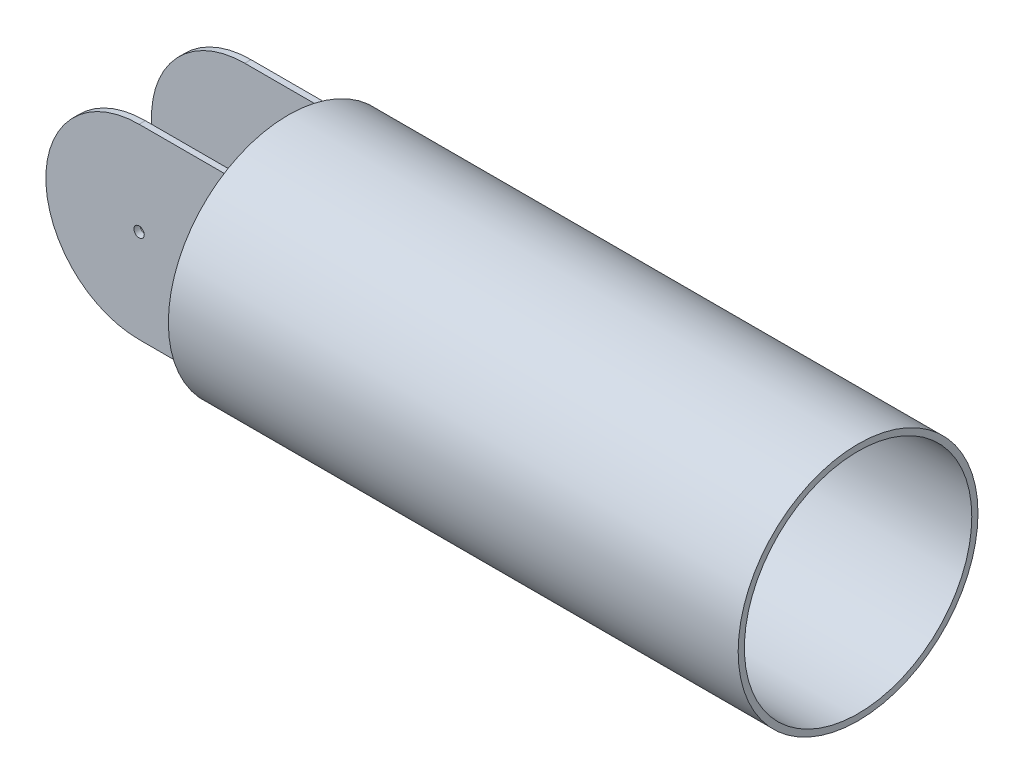
from build123d import *

# Parameters (mm, degrees)
IZIM10_W                    = 180
IZIM10_H                    = 180
Y_KSEKLIK_EKSTR_ZYON1_DEPTH = 108
KES_EKSTR_ZYON7_DEPTH       = 108
IZIM13_R                    = 115.75
Y_KSEKLIK_EKSTR_ZYON2_DEPTH = 550
IZIM14_R                    = 109.75
KES_EKSTR_ZYON8_DEPTH       = 294
IZIM15_W                    = 180
IZIM15_H                    = 96
KES_EKSTR_ZYON9_DEPTH       = 294
IZIM16_R                    = 5
KES_EKSTR_ZYON10_DEPTH      = 294


with BuildPart() as part:
    # Çizim10 → Yükseklik-Ekstrüzyon1 (new body)
    with BuildSketch(Plane.XY):
        with Locations((90, 90)):
            Rectangle(IZIM10_W, IZIM10_H)
    extrude(amount=Y_KSEKLIK_EKSTR_ZYON1_DEPTH)

    # Çizim11 → Kes-Ekstrüzyon7 (cut)
    with BuildSketch(Plane.XY.offset(108)):
        with BuildLine():
            ThreePointArc((0, 90), (26.360389693, 153.639610307), (90, 180))
            Line((90, 180), (0, 180))
            Line((0, 180), (0, 90))
        make_face()
        with BuildLine():
            ThreePointArc((90, 0), (26.360389693, 26.360389693), (0, 90))
            Line((0, 90), (0, 0))
            Line((0, 0), (90, 0))
        make_face()
    extrude(amount=-KES_EKSTR_ZYON7_DEPTH, mode=Mode.SUBTRACT)

    # Çizim13 → Yükseklik-Ekstrüzyon2 (add)
    with BuildSketch(Plane(origin=(180, 0, 0), x_dir=(0, 0, -1), z_dir=(1, 0, 0))):
        with Locations((-54, 90)):
            Circle(IZIM13_R)
    extrude(amount=Y_KSEKLIK_EKSTR_ZYON2_DEPTH)

    # Çizim14 → Kes-Ekstrüzyon8 (cut)
    with BuildSketch(Plane(origin=(730, 0, 0), x_dir=(0, 0, -1), z_dir=(1, 0, 0))):
        with Locations((-54, 90)):
            Circle(IZIM14_R)
    extrude(amount=-KES_EKSTR_ZYON8_DEPTH, mode=Mode.SUBTRACT)

    # Çizim15 → Kes-Ekstrüzyon9 (cut)
    with BuildSketch(Plane(origin=(0, 180, 0), x_dir=(1, 0, 0), z_dir=(0, 1, 0))):
        with Locations((90, -54)):
            Rectangle(IZIM15_W, IZIM15_H)
    extrude(amount=-KES_EKSTR_ZYON9_DEPTH, mode=Mode.SUBTRACT)

    # Çizim16 → Kes-Ekstrüzyon10 (cut)
    with BuildSketch(Plane.XY.offset(108)):
        with Locations((90, 90)):
            Circle(IZIM16_R)
    extrude(amount=-KES_EKSTR_ZYON10_DEPTH, mode=Mode.SUBTRACT)


solid = part.part
